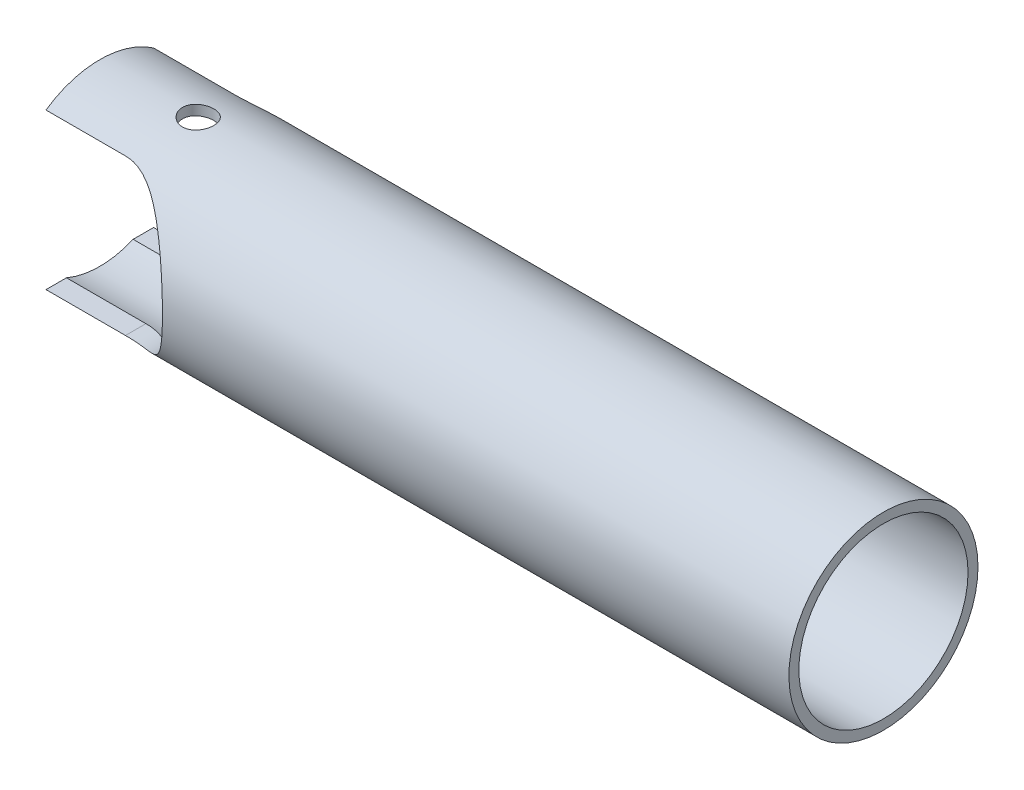
from build123d import *

# Parameters (mm, degrees)
SKETCH1_R               = 1.2065
SKETCH1_R_2             = 1.0795
BOSS_EXTRUDE1_DEPTH     = 10
CUT_EXTRUDE4_DEPTH      = 10
CUT_EXTRUDE4_DEPTH_BACK = 10
CUT_EXTRUDE5_DEPTH      = 10
CUT_EXTRUDE5_DEPTH_BACK = 10
SKETCH6_R               = 0.2


with BuildPart() as part:
    # Sketch1 → Boss-Extrude1 (new body)
    with BuildSketch(Plane(origin=(0, 0, 0), x_dir=(0, 0, -1), z_dir=(1, 0, 0))):
        Circle(SKETCH1_R)
        Circle(SKETCH1_R_2, mode=Mode.SUBTRACT)
    extrude(amount=BOSS_EXTRUDE1_DEPTH)

    # Sketch5 → Cut-Extrude4 (cut, two sides: drawn at the far end of the back side and taken through both)
    with BuildSketch(Plane.XY.offset(-CUT_EXTRUDE4_DEPTH_BACK)):
        with BuildLine():
            Line((1.013670485, 0.9921875), (0, 0.9921875))
            Line((0, 0.9921875), (0, -0.9921875))
            Line((0, -0.9921875), (1.013670485, -0.9921875))
            ThreePointArc((1.013670485, -0.9921875), (2.005857985, 0), (1.013670485, 0.9921875))
        make_face()
    extrude(amount=CUT_EXTRUDE4_DEPTH + CUT_EXTRUDE4_DEPTH_BACK, mode=Mode.SUBTRACT)

    # Sketch6 → Cut-Extrude5 (cut, two sides: drawn at the far end of the back side and taken through both)
    with BuildSketch(Plane(origin=(0, 0, 0), x_dir=(1, 0, 0), z_dir=(0, 1, 0)).offset(-CUT_EXTRUDE5_DEPTH_BACK)):
        with Locations((1.255857985, 0)):
            Circle(SKETCH6_R)
    extrude(amount=CUT_EXTRUDE5_DEPTH + CUT_EXTRUDE5_DEPTH_BACK, mode=Mode.SUBTRACT)


solid = part.part
